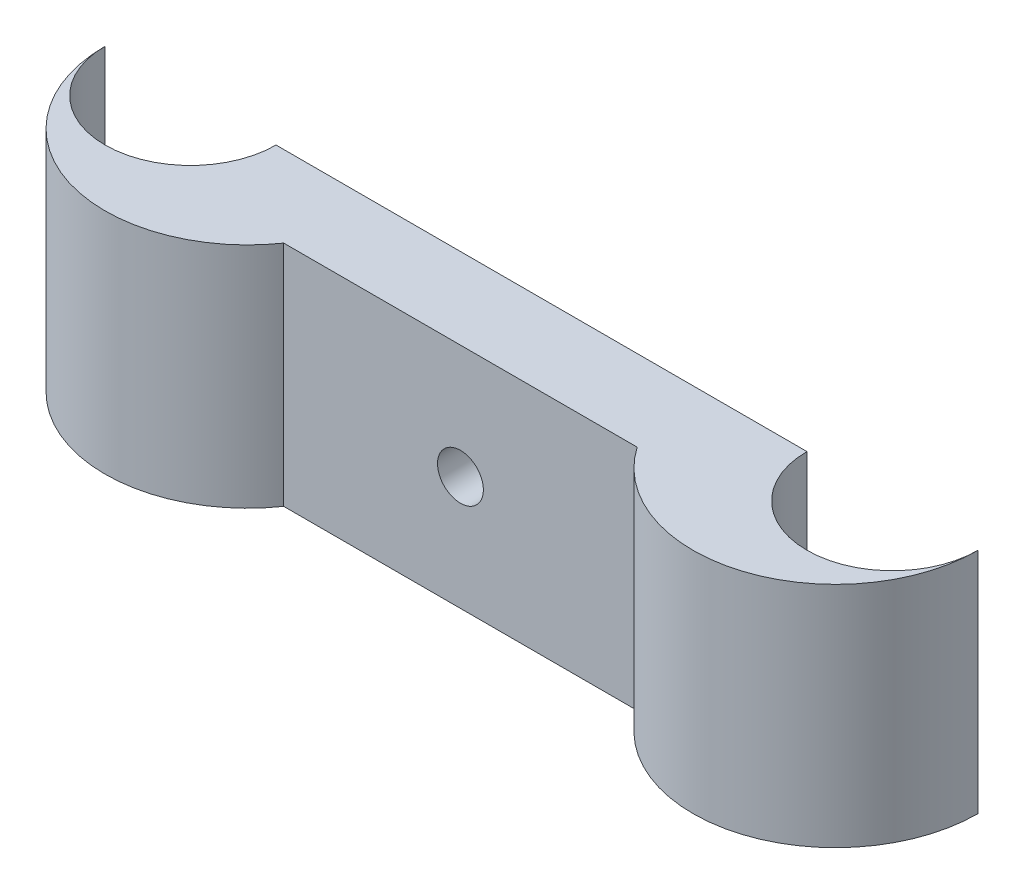
from build123d import *

# Parameters (mm, degrees)
BOSS_EXTRUDE1_DEPTH = 20
SKETCH2_R           = 2.01
CUT_EXTRUDE1_DEPTH  = 20


with BuildPart() as part:
    # Sketch1 → Boss-Extrude1 (new body)
    with BuildSketch(Plane(origin=(0, 0, 0), x_dir=(1, 0, 0), z_dir=(0, 1, 0))):
        with BuildLine():
            Line((-23.28, 0), (23.28, 0))
            ThreePointArc((23.28, 0), (30.78, -7.5), (38.28, 0))
            ThreePointArc((38.28, 0), (29.504120366, -11.932347946), (15.4990516, -7.11))
            Line((15.4990516, -7.11), (-15.4990516, -7.11))
            ThreePointArc((-15.4990516, -7.11), (-29.504120366, -11.932347946), (-38.28, 0))
            ThreePointArc((-38.28, 0), (-30.78, -7.5), (-23.28, 0))
        make_face()
    extrude(amount=BOSS_EXTRUDE1_DEPTH)

    # Sketch2 → Cut-Extrude1 (cut)
    with BuildSketch(Plane(origin=(0, 0, 0), x_dir=(-1, 0, 0), z_dir=(0, 0, -1))):
        with Locations((0, 10)):
            Circle(SKETCH2_R)
    extrude(amount=-CUT_EXTRUDE1_DEPTH, mode=Mode.SUBTRACT)


solid = part.part
